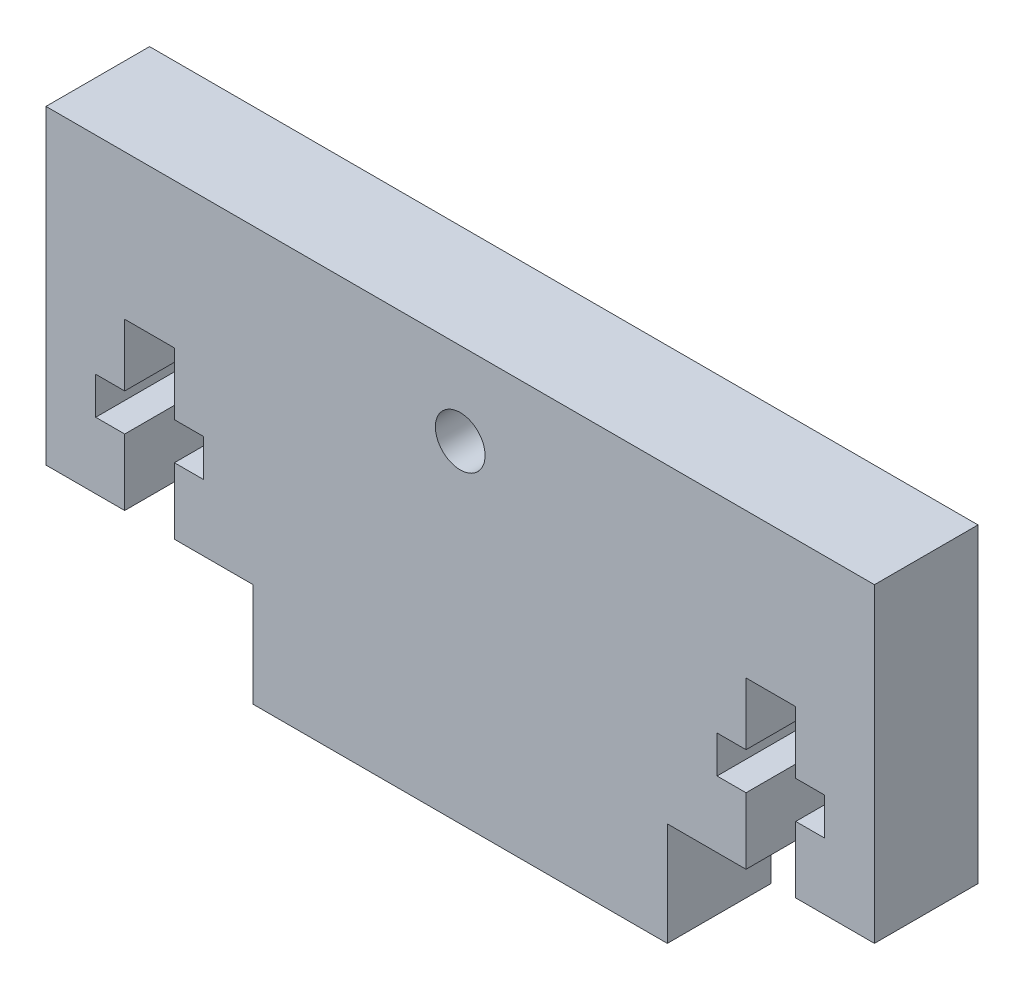
from build123d import *

# Parameters (mm, degrees)
BOSS_EXTRUDE1_DEPTH = 6.35
SKETCH2_R           = 1.524
CUT_EXTRUDE1_DEPTH  = 7.35


with BuildPart() as part:
    # Sketch1 → Boss-Extrude1 (new body)
    with BuildSketch(Plane.XY):
        Polygon((50.8, 25.4), (0, 25.4), (0, 6.35), (4.826, 6.35), (4.826, 10.414), (3.048, 10.414), (3.048, 12.7), (4.826, 12.7), (4.826, 16.51), (7.874, 16.51), (7.874, 12.7), (9.652, 12.7), (9.652, 10.414), (7.874, 10.414), (7.874, 6.35), (12.7, 6.35), (12.7, 0), (38.1, 0), (38.1, 6.35), (42.926, 6.35), (42.926, 10.414), (41.148, 10.414), (41.148, 12.7), (42.926, 12.7), (42.926, 16.51), (45.974, 16.51), (45.974, 12.7), (47.752, 12.7), (47.752, 10.414), (45.974, 10.414), (45.974, 6.35), (50.8, 6.35), align=None)
    extrude(amount=BOSS_EXTRUDE1_DEPTH)

    # Sketch2 → Cut-Extrude1 (cut, through all)
    with BuildSketch(Plane.XY.offset(6.35)):
        with Locations((25.4, 20.32)):
            Circle(SKETCH2_R)
    extrude(amount=-CUT_EXTRUDE1_DEPTH, mode=Mode.SUBTRACT)


solid = part.part
